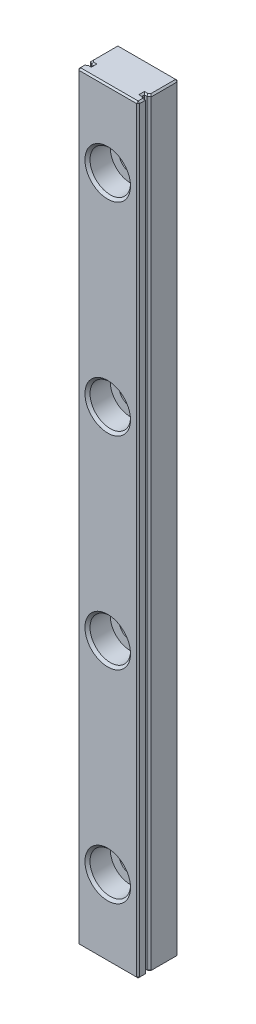
from build123d import *

# Parameters (mm, degrees)
SKETCH_1_W                         = 12
SKETCH_1_H                         = 8
EXTRUDE_1_DEPTH                    = 150
CUT_EXTRUDE_1_DEPTH                = 151
CHAMFER_1_SIZE                     = 0.5
PATTERN_LINEAR_1_COUNT             = 4
PATTERN_LINEAR_1_PITCH             = 40
CHAMFER_1_OF_PATTERN_LINEAR_1_SIZE = 0.5
CHAMFER_2_SIZE                     = 0.3


with BuildPart() as part:
    # Эскиз1 → Бобышка-Вытянуть1 (new body)
    with BuildSketch(Plane(origin=(0, 0, 0), x_dir=(1, 0, 0), z_dir=(0, 1, 0))):
        with Locations((6, 4)):
            Rectangle(SKETCH_1_W, SKETCH_1_H)
    extrude(amount=EXTRUDE_1_DEPTH)

    # Эскиз2 → Вырез-Вытянуть1 (cut, through all)
    with BuildSketch(Plane(origin=(0, 150, 0), x_dir=(1, 0, 0), z_dir=(0, 1, 0))):
        with BuildLine():
            Line((11, 2.25), (11, 1.75))
            Line((11, 1.75), (11.5, 1.75))
            ThreePointArc((11.5, 1.75), (11.706107374, 1.524471742), (12, 1.440983006))
            Line((12, 1.440983006), (12, 2.559016994))
            ThreePointArc((12, 2.559016994), (11.706107374, 2.475528258), (11.5, 2.25))
            Line((11.5, 2.25), (11, 2.25))
        make_face()
    cut_extrude_1 = extrude(amount=-CUT_EXTRUDE_1_DEPTH, mode=Mode.SUBTRACT)

    # Зеркальное отражение1: Вырез-Вытянуть1 across plane
    add(cut_extrude_1.mirror(Plane(origin=(6, 0, 0), x_dir=(0, 0, 1), z_dir=(1, 0, 0))), mode=Mode.SUBTRACT)

    # Эскиз4 → Вырез-Повернуть1 (revolve, cut)
    with BuildSketch(Plane(origin=(6, 0, 0), x_dir=(0, 0, -1), z_dir=(1, 0, 0))):
        Polygon((0, 139), (4.5, 139), (4.5, 137.25), (8, 137.25), (8, 135), (0, 135), align=None)
    cut_revolve_1 = revolve(axis=Axis((6, 135, -8), (0, 0, 1)), mode=Mode.SUBTRACT)

    # Фаска1
    chamfer_1_edges = [part.edges().sort_by_distance(p)[0] for p in [
        (6, 131, 0),
        (6, 132.75, -8),
    ]]
    chamfer(chamfer_1_edges, length=CHAMFER_1_SIZE)

    # Линейный массив1: Вырез-Повернуть1 ×4
    with Locations(*[(0, -i * PATTERN_LINEAR_1_PITCH, 0) for i in range(1, PATTERN_LINEAR_1_COUNT)]):
        add(cut_revolve_1, mode=Mode.SUBTRACT)

    # Фаска1 of Линейный массив1
    chamfer_1_of_pattern_linear_1_edges = [part.edges().sort_by_distance(p)[0] for p in [
        (6, 91, 0),
        (6, 92.75, -8),
        (6, 51, 0),
        (6, 52.75, -8),
        (6, 11, 0),
        (6, 12.75, -8),
    ]]
    chamfer(chamfer_1_of_pattern_linear_1_edges, length=CHAMFER_1_OF_PATTERN_LINEAR_1_SIZE)

    # Фаска2
    chamfer_2_edges = [part.edges().sort_by_distance(p)[0] for p in [
        (12, 150, -0.720491503),
        (6, 150, -8),
        (12, 0, -5.279508497),
        (12, 150, -5.279508497),
        (11.25, 0, -2.25),
        (11.706107374, 0, -2.475528258),
        (11.706107374, 0, -1.524471742),
        (11.25, 0, -1.75),
        (11, 0, -2),
        (11.25, 150, -2.25),
        (11, 150, -2),
        (11.25, 150, -1.75),
        (11.706107374, 150, -1.524471742),
        (11.706107374, 150, -2.475528258),
        (0, 0, -0.720491503),
        (0, 150, -0.720491503),
        (0, 150, -5.279508497),
        (0.75, 150, -2.25),
        (1, 150, -2),
        (0.75, 150, -1.75),
        (0.293892626, 150, -1.524471742),
        (0.293892626, 150, -2.475528258),
        (0.75, 0, -2.25),
        (6, 0, -8),
        (1, 0, -2),
        (0.75, 0, -1.75),
        (0.293892626, 0, -1.524471742),
        (0.293892626, 0, -2.475528258),
        (12, 0, -0.720491503),
        (6, 0, 0),
        (0, 0, -5.279508497),
        (6, 150, 0),
        (0, 75, -8),
        (12, 75, -8),
        (12, 75, 0),
        (0, 75, 0),
    ]]
    chamfer(chamfer_2_edges, length=CHAMFER_2_SIZE)


solid = part.part
